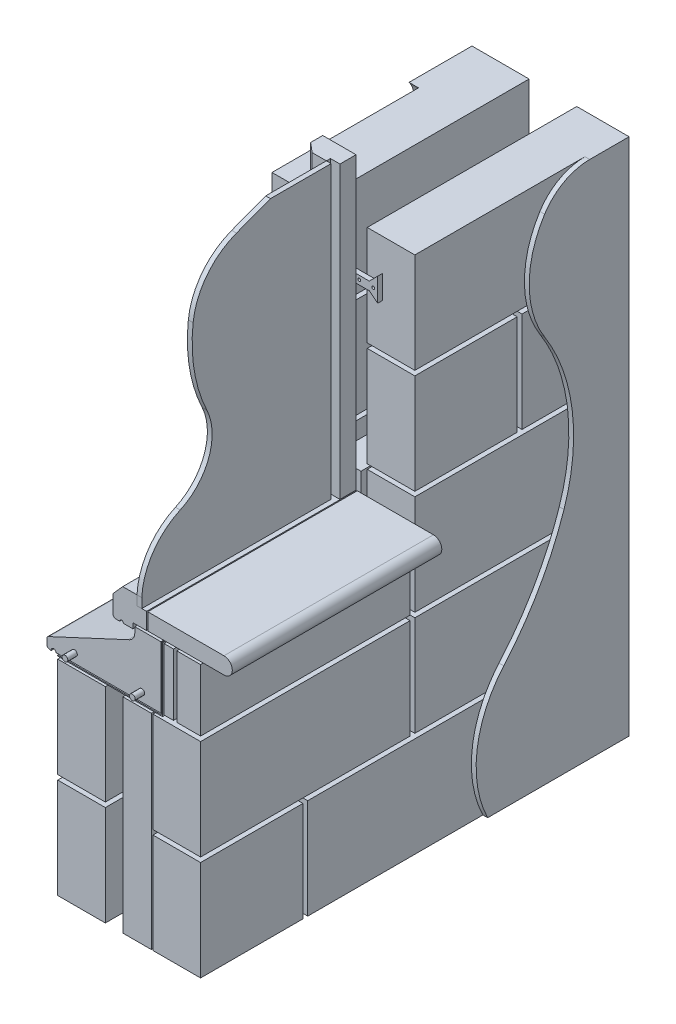
from build123d import *

# Parameters (mm, degrees)
SKETCH1_W               = 100
SKETCH1_H               = 210
EXTRUDE1_DEPTH          = 440
EXTRUDE1_2_DEPTH        = 440
SKETCH2_W               = 100
SKETCH2_H               = 210
EXTRUDE2_DEPTH          = 215
EXTRUDE2_2_DEPTH        = 215
EXTRUDE3_DEPTH          = 440
EXTRUDE4_DEPTH          = 440
SKETCH5_W               = 20
SKETCH5_H               = 130
EXTRUDE5_DEPTH          = 440
SKETCH5_W_2             = 50
EXTRUDE5_2_DEPTH        = 440
EXTRUDE6_DEPTH          = 440
EXTRUDE7_DEPTH          = 440
SKETCH14_W              = 440
SKETCH14_H              = 210
EXTRUDE13_DEPTH         = 100
SKETCH15_W              = 440
SKETCH15_H              = 210
EXTRUDE14_DEPTH         = 100
SKETCH16_W              = 215
SKETCH16_H              = 210
EXTRUDE15_DEPTH         = 100
SKETCH17_W              = 215
SKETCH17_H              = 210
EXTRUDE16_DEPTH         = 100
SKETCH18_W              = 440
SKETCH18_H              = 210.148316257
EXTRUDE17_DEPTH         = 100
SKETCH19_W              = 440
SKETCH19_H              = 210.148316257
EXTRUDE18_DEPTH         = 100
SKETCH8_R               = 6
EXTRUDE19_DEPTH         = 20
SKETCH20_W              = 440
SKETCH20_H              = 210
EXTRUDE20_DEPTH         = 100
SKETCH21_W              = 440
SKETCH21_H              = 210
EXTRUDE21_DEPTH         = 100
SKETCH24_W              = 60
SKETCH24_H              = 429.83298548
EXTRUDE23_DEPTH         = 440
SKETCH25_W              = 60.321900772
SKETCH25_H              = 650.148316257
EXTRUDE26_DEPTH         = 450
SKETCH26_W              = 215
SKETCH26_H              = 210
EXTRUDE27_DEPTH         = 100
EXTRUDE27_2_DEPTH       = 100
SKETCH28_W              = 215
SKETCH28_H              = 210
EXTRUDE29_DEPTH         = 100
EXTRUDE29_2_DEPTH       = 100
SKETCH29_W              = 440
SKETCH29_H              = 210
EXTRUDE30_DEPTH         = 100
SKETCH30_W              = 440
SKETCH30_H              = 210
EXTRUDE31_DEPTH         = 100
EXTRUDE32_DEPTH         = 610
SKETCH32_W              = 397.749306711
SKETCH32_H              = 610.511662393
EXTRUDE35_DEPTH         = 10
EXTRUDE36_DEPTH         = 40
CUT_EXTRUDE1_DEPTH      = 738.093699322
CUT_EXTRUDE1_DEPTH_BACK = 173.906300678
SKETCH35_R              = 3
EXTRUDE37_DEPTH         = 10
CUT_EXTRUDE3_DEPTH      = 10
EXTRUDE38_DEPTH         = 10


with BuildPart() as part:
    # Sketch1 → Extrude1 (new body)
    with BuildSketch(Plane.XY):
        with Locations((50, 105)):
            Rectangle(SKETCH1_W, SKETCH1_H)
    extrude(amount=-EXTRUDE1_DEPTH)


with BuildPart() as body_2:
    # Sketch1 → Extrude1 2 (new body)
    with BuildSketch(Plane.XY):
        with Locations((250, 105)):
            Rectangle(SKETCH1_W, SKETCH1_H)
    extrude(amount=-EXTRUDE1_2_DEPTH)


with BuildPart() as body_3:
    # Sketch2 → Extrude2 (new body)
    with BuildSketch(Plane.XY):
        with Locations((50, -115)):
            Rectangle(SKETCH2_W, SKETCH2_H)
    extrude(amount=-EXTRUDE2_DEPTH)


with BuildPart() as body_4:
    # Sketch2 → Extrude2 2 (new body)
    with BuildSketch(Plane.XY):
        with Locations((250, -115)):
            Rectangle(SKETCH2_W, SKETCH2_H)
    extrude(amount=-EXTRUDE2_2_DEPTH)


with BuildPart() as body_5:
    # Sketch3 → Extrude3 (new body)
    with BuildSketch(Plane.XY):
        with BuildLine():
            Line((216.823138015, 220), (216.823138015, 350))
            Line((216.823138015, 350), (161.823138015, 350))
            Line((161.823138015, 350), (161.823138015, 338.393794976))
            ThreePointArc((161.823138015, 338.393794976), (158.070702256, 326.731177079), (148.221472393, 319.444881625))
            Line((148.221472393, 319.444881625), (-18.869604897, 241.550219633))
            ThreePointArc((-18.869604897, 241.550219633), (-25.49651836, 227.995282497), (-13.63110911, 218.675177017))
            ThreePointArc((-13.63110911, 218.675177017), (-9.416600227, 224.722231218), (-3.757140715, 220))
            Line((-3.757140715, 220), (216.823138015, 220))
        make_face()
    extrude(amount=-EXTRUDE3_DEPTH)

    # Sketch8 → Extrude19 (add)
    with BuildSketch(Plane.XY):
        with Locations(Location((35.155290968, 238.788078717, 0), (0, 0, 180))):  # turned: the seam where the file's is
            Circle(SKETCH8_R)
        with Locations(Location((176.497119411, 238.788078717, 0), (0, 0, 180))):  # turned: the seam where the file's is
            Circle(SKETCH8_R)
    extrude(amount=EXTRUDE19_DEPTH)



with BuildPart() as body_6:
    # Sketch4 → Extrude4 (new body)
    with BuildSketch(Plane.XY):
        with BuildLine():
            Line((186.507724197, 390.164193313), (186.507724197, 355.164193313))
            Line((186.507724197, 355.164193313), (158.026096596, 355.164193313))
            Line((158.026096596, 355.164193313), (158.026096596, 343.974696516))
            Line((158.026096596, 343.974696516), (138.026096596, 343.974696516))
            ThreePointArc((138.026096596, 343.974696516), (134.026096596, 347.974696516), (130.026096596, 343.974696516))
            Line((130.026096596, 343.974696516), (120.026096596, 343.974696516))
            Line((120.026096596, 343.974696516), (116.507724197, 347.803513538))
            Line((116.507724197, 347.803513538), (116.507724197, 387.803513538))
            Line((116.507724197, 387.803513538), (136.507724197, 410.164193313))
            Line((136.507724197, 410.164193313), (166.507724197, 410.164193313))
            Line((166.507724197, 410.164193313), (166.507724197, 390.164193313))
            Line((166.507724197, 390.164193313), (186.507724197, 390.164193313))
        make_face()
    extrude(amount=-EXTRUDE4_DEPTH)


with BuildPart() as body_7:
    # Sketch5 → Extrude5 (new body)
    with BuildSketch(Plane.XY):
        with Locations((233.161862968, 285)):
            Rectangle(SKETCH5_W, SKETCH5_H)
    extrude(amount=-EXTRUDE5_DEPTH)


with BuildPart() as body_8:
    # Sketch5 → Extrude5 2 (new body)
    with BuildSketch(Plane.XY):
        with Locations((275, 285)):
            Rectangle(SKETCH5_W_2, SKETCH5_H)
    extrude(amount=-EXTRUDE5_2_DEPTH)


with BuildPart() as body_9:
    # Sketch6 → Extrude6 (new body)
    with BuildSketch(Plane.XY):
        Polygon((0, 217.62172998), (218.355896295, 217.62172998), (218.355896295, 350), (220.20226962, 350), (220.20226962, 215.409937456), (0, 215.409937456), align=None)
    extrude(amount=-EXTRUDE6_DEPTH)


with BuildPart() as body_10:
    # Sketch7 → Extrude7 (new body)
    with BuildSketch(Plane.XY):
        with BuildLine():
            Line((189.109371037, 355.675855706), (189.109371037, 390.675855706))
            Line((189.109371037, 390.675855706), (349.109371037, 390.675855706))
            ThreePointArc((349.109371037, 390.675855706), (366.609371037, 373.175855706), (349.109371037, 355.675855706))
            Line((349.109371037, 355.675855706), (189.109371037, 355.675855706))
        make_face()
    extrude(amount=-EXTRUDE7_DEPTH)


with BuildPart() as body_11:
    # Sketch14 → Extrude13 (new body)
    with BuildSketch(Plane.ZY):
        with Locations((-445, -115)):
            Rectangle(SKETCH14_W, SKETCH14_H)
    extrude(amount=-EXTRUDE13_DEPTH)


with BuildPart() as body_12:
    # Sketch15 → Extrude14 (new body)
    with BuildSketch(Plane(origin=(300, 0, 0), x_dir=(0, 0, -1), z_dir=(1, 0, 0))):
        with Locations((445, -115)):
            Rectangle(SKETCH15_W, SKETCH15_H)
    extrude(amount=-EXTRUDE14_DEPTH)



with BuildPart() as body_13:
    # Sketch16 → Extrude15 (new body)
    with BuildSketch(Plane.ZY):
        with Locations((-782.5, -115)):
            Rectangle(SKETCH16_W, SKETCH16_H)
    extrude(amount=-EXTRUDE15_DEPTH)



with BuildPart() as body_14:
    # Sketch17 → Extrude16 (new body)
    with BuildSketch(Plane(origin=(300, 0, 0), x_dir=(0, 0, -1), z_dir=(1, 0, 0))):
        with Locations((782.5, -115)):
            Rectangle(SKETCH17_W, SKETCH17_H)
    extrude(amount=-EXTRUDE16_DEPTH)


with BuildPart() as body_15:
    # Sketch18 → Extrude17 (new body)
    with BuildSketch(Plane.ZY):
        with Locations((-670, 105.074158129)):
            Rectangle(SKETCH18_W, SKETCH18_H)
    extrude(amount=-EXTRUDE17_DEPTH)


with BuildPart() as body_16:
    # Sketch19 → Extrude18 (new body)
    with BuildSketch(Plane(origin=(300, 0, 0), x_dir=(0, 0, -1), z_dir=(1, 0, 0))):
        with Locations((670, 105.074158129)):
            Rectangle(SKETCH19_W, SKETCH19_H)
    extrude(amount=-EXTRUDE18_DEPTH)


with BuildPart() as body_17:
    # Sketch20 → Extrude20 (new body)
    with BuildSketch(Plane.ZY):
        with Locations((-670, 325.148316257)):
            Rectangle(SKETCH20_W, SKETCH20_H)
    extrude(amount=-EXTRUDE20_DEPTH)


with BuildPart() as body_18:
    # Sketch21 → Extrude21 (new body)
    with BuildSketch(Plane(origin=(300, 0, 0), x_dir=(0, 0, -1), z_dir=(1, 0, 0))):
        with Locations((670, 325.148316257)):
            Rectangle(SKETCH21_W, SKETCH21_H)
    extrude(amount=-EXTRUDE21_DEPTH)


with BuildPart() as body_19:
    # Sketch24 → Extrude23 (new body)
    with BuildSketch(Plane.XY):
        with Locations((166.829624969, -5.08350726)):
            Rectangle(SKETCH24_W, SKETCH24_H)
    extrude(amount=-EXTRUDE23_DEPTH)


with BuildPart() as body_5_1:
    add(body_5.part)

    add(body_6.part)  # Extrude26 merges body 6

    add(body_9.part)  # Extrude26 merges body 9

    add(body_10.part)  # Extrude26 merges body 10

    add(body_19.part)  # Extrude26 merges body 19
    # Sketch25 → Extrude26 (add)
    with BuildSketch(Plane(origin=(0, 0, -890), x_dir=(-1, 0, 0), z_dir=(0, 0, -1))):
        with Locations((-166.668674583, 105.074158129)):
            Rectangle(SKETCH25_W, SKETCH25_H)
    extrude(amount=-EXTRUDE26_DEPTH)

    # Sketch31 → Extrude32 (add)
    with BuildSketch(Plane(origin=(0, 390.675855706, 0), x_dir=(-1, 0, 0), z_dir=(0, 1, 0))):
        Polygon((-116.507724197, -440), (-116.507724197, -414.610094287), (-136.507724197, -397.749306711), (-166.507724197, -397.749306711), (-166.507724197, -406.179700499), (-186.507724197, -406.179700499), (-186.507724197, -440), align=None)
    extrude(amount=EXTRUDE32_DEPTH)


with BuildPart() as body_16_2:
    # Sketch26 → Extrude27 (new body)
    with BuildSketch(Plane.ZY):
        with Locations((-557.5, 545.148316257)):
            Rectangle(SKETCH26_W, SKETCH26_H)
    extrude(amount=-EXTRUDE27_DEPTH)


with BuildPart() as body_17_2:
    # Sketch26 → Extrude27 2 (new body)
    with BuildSketch(Plane.ZY):
        with Locations((-782.5, 545.148316257)):
            Rectangle(SKETCH26_W, SKETCH26_H)
    extrude(amount=-EXTRUDE27_2_DEPTH)


with BuildPart() as body_18_2:
    # Sketch28 → Extrude29 (new body)
    with BuildSketch(Plane(origin=(300, 0, 0), x_dir=(0, 0, -1), z_dir=(1, 0, 0))):
        with Locations((557.5, 545.148316257)):
            Rectangle(SKETCH28_W, SKETCH28_H)
    extrude(amount=-EXTRUDE29_DEPTH)


with BuildPart() as body_19_2:
    # Sketch28 → Extrude29 2 (new body)
    with BuildSketch(Plane(origin=(300, 0, 0), x_dir=(0, 0, -1), z_dir=(1, 0, 0))):
        with Locations((782.5, 545.148316257)):
            Rectangle(SKETCH28_W, SKETCH28_H)
    extrude(amount=-EXTRUDE29_2_DEPTH)


with BuildPart() as body_20:
    # Sketch29 → Extrude30 (new body)
    with BuildSketch(Plane.ZY):
        with Locations((-670, 765.148316257)):
            Rectangle(SKETCH29_W, SKETCH29_H)
    extrude(amount=-EXTRUDE30_DEPTH)


with BuildPart() as body_21:
    # Sketch30 → Extrude31 (new body)
    with BuildSketch(Plane(origin=(300, 0, 0), x_dir=(0, 0, -1), z_dir=(1, 0, 0))):
        with Locations((670, 765.148316257)):
            Rectangle(SKETCH30_W, SKETCH30_H)
    extrude(amount=-EXTRUDE31_DEPTH)


with BuildPart() as body_22:
    # Sketch32 → Extrude35 (new body)
    with BuildSketch(Plane(origin=(166.507724197, 0, 0), x_dir=(0, 0, -1), z_dir=(1, 0, 0))):
        with Locations((198.874653356, 695.42002451)):
            Rectangle(SKETCH32_W, SKETCH32_H)
    extrude(amount=EXTRUDE35_DEPTH)

    # Sketch36 → Cut-Extrude3 (cut)
    with BuildSketch(Plane.ZY.offset(-166.507724197)):
        with BuildLine():
            Line((-270.257297848, 1000.675855706), (-198.874653356, 973.707696946))
            ThreePointArc((-198.874653356, 973.707696946), (-136.785707689, 927.870625384), (-107.771320383, 856.356713222))
            ThreePointArc((-107.771320383, 856.356713222), (-110.204975045, 767.455927563), (-136.785707689, 682.586987322))
            ThreePointArc((-136.785707689, 682.586987322), (-140.819684885, 594.130367098), (-80.690324139, 529.128008605))
            ThreePointArc((-80.690324139, 529.128008605), (-23.674697924, 480.95327997), (0, 410.164193313))
            Line((0, 410.164193313), (0, 1000.675855706))
            Line((0, 1000.675855706), (-270.257297848, 1000.675855706))
        make_face()
    extrude(amount=-CUT_EXTRUDE3_DEPTH, mode=Mode.SUBTRACT)


with BuildPart() as body_13_1:
    add(body_13.part)

    add(body_15.part)  # Extrude36 merges body 15

    add(body_17.part)  # Extrude36 merges body 17

    add(body_17_2.part)  # Extrude36 merges body 17 2

    add(body_20.part)  # Extrude36 merges body 20
    # Sketch33 → Extrude36 (add)
    with BuildSketch(Plane.ZY):
        with BuildLine():
            Line((-890, 870.148316257), (-890, -220))
            Line((-890, -220), (-717.093699322, -220))
            Line((-717.093699322, -220), (-717.093699322, -105.018608156))
            ThreePointArc((-717.093699322, -105.018608156), (-727.319921284, 17.4139572), (-757.715192024, 136.453598463))
            ThreePointArc((-757.715192024, 136.453598463), (-775.082149001, 286.671156213), (-727.319921284, 430.148316257))
            ThreePointArc((-727.319921284, 430.148316257), (-680.947017697, 627.795289842), (-757.715192024, 815.735226431))
            ThreePointArc((-757.715192024, 815.735226431), (-767.5987585, 842.941771344), (-757.715192024, 870.148316257))
            Line((-757.715192024, 870.148316257), (-890, 870.148316257))
        make_face()
    extrude(amount=EXTRUDE36_DEPTH)


with BuildPart() as cut_extrude1_tool:
    # Sketch34 → Cut-Extrude1 (new body, two sides)
    with BuildSketch(Plane.XY.offset(-717.093699322)) as cut_extrude1_sk:
        Polygon((-622.198816694, -2736.770168097), (-40, -220), (-24.364648207, -152.410396874), (-20, 870.148316257), (-8.97393759, 3453.356779995), (-5150.271502365, 3962.679384206), (-5763.496381469, -2227.447563886), align=None)
    extrude(amount=CUT_EXTRUDE1_DEPTH)
    extrude(cut_extrude1_sk.sketch, amount=-CUT_EXTRUDE1_DEPTH_BACK)


with BuildPart() as body_5_2:
    add(body_5_1.part)

    # Cut-Extrude1: cut by cut_extrude1_tool
    add(cut_extrude1_tool.part, mode=Mode.SUBTRACT)


with BuildPart() as body_13_2:
    add(body_13_1.part)

    # Cut-Extrude1: cut by cut_extrude1_tool
    add(cut_extrude1_tool.part, mode=Mode.SUBTRACT)


with BuildPart() as body_19_3:
    # Sketch35 → Extrude37 (new body)
    with BuildSketch(Plane(origin=(0, 0, -440), x_dir=(-1, 0, 0), z_dir=(0, 0, -1))):
        Polygon((-214.247396682, 784.704849859), (-84.909487462, 784.704849859), (-67.343031027, 802.271306297), (-67.343031027, 753.085228274), (-84.909487462, 767.138393425), (-214.247396685, 767.138393425), (-231.813853122, 753.085228276), (-231.813853122, 802.271306296), align=None)
        with Locations((-222.624950506, 776.698822484)):
            Circle(SKETCH35_R, mode=Mode.SUBTRACT)
        with Locations((-193.269293863, 776.698822484)):
            Circle(SKETCH35_R, mode=Mode.SUBTRACT)
        with Locations((-150.319406962, 776.698822484)):
            Circle(SKETCH35_R, mode=Mode.SUBTRACT)
        with Locations((-108.9456627, 776.698822484)):
            Circle(SKETCH35_R, mode=Mode.SUBTRACT)
        with Locations((-76.043685121, 776.698822484)):
            Circle(SKETCH35_R, mode=Mode.SUBTRACT)
    extrude(amount=EXTRUDE37_DEPTH)


with BuildPart() as body_12_1:
    add(body_12.part)

    add(body_14.part)  # Extrude38 merges body 14

    add(body_16.part)  # Extrude38 merges body 16

    add(body_18.part)  # Extrude38 merges body 18

    add(body_19_2.part)  # Extrude38 merges body 19 2

    add(body_21.part)  # Extrude38 merges body 21
    # Sketch37 → Extrude38 (add)
    with BuildSketch(Plane(origin=(300, 0, 0), x_dir=(0, 0, -1), z_dir=(1, 0, 0))):
        with BuildLine():
            Line((890, -220), (890, 870.148316257))
            Line((890, 870.148316257), (807.363723357, 870.148316257))
            ThreePointArc((807.363723357, 870.148316257), (753.270761738, 856.248234891), (712.580236503, 817.991968542))
            ThreePointArc((712.580236503, 817.991968542), (680.17350508, 706.282859035), (712.580236503, 594.573749528))
            ThreePointArc((712.580236503, 594.573749528), (770.573922401, 432.160916152), (753.270761738, 260.57479585))
            ThreePointArc((753.270761738, 260.57479585), (700.982925445, 143.741693346), (626.823748396, 39.413326522))
            ThreePointArc((626.823748396, 39.413326522), (570.713486285, -85.180072666), (592.972503091, -220))
            Line((592.972503091, -220), (890, -220))
        make_face()
    extrude(amount=EXTRUDE38_DEPTH)


solid = Compound([part.part, body_2.part, body_3.part, body_4.part, body_7.part, body_8.part, body_11.part, body_16_2.part, body_18_2.part, body_22.part, body_5_2.part, body_13_2.part, body_19_3.part, body_12_1.part])
